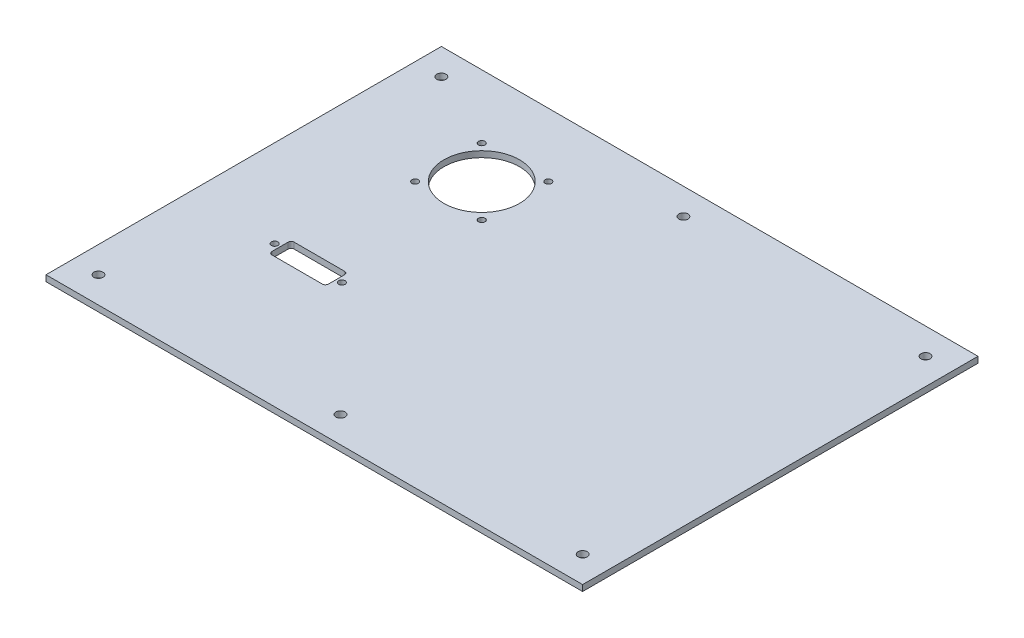
from build123d import *

# Parameters (mm, degrees)
SKETCH_1_W          = 266
SKETCH_1_H          = 196
SKETCH_1_R          = 2.25
EXTRUDE_1_DEPTH     = 3
SKETCH_3_R          = 18.75
SKETCH_3_R_2        = 1.6
CUT_EXTRUDE_1_DEPTH = 4
SKETCH1_R           = 1.6
SKETCH1_W           = 28
SKETCH1_H           = 11
CUT_EXTRUDE1_DEPTH  = 4
FILLET1_R           = 1.5


with BuildPart() as part:
    # Эскиз1 → Бобышка-Вытянуть1 (new body)
    with BuildSketch(Plane(origin=(0, 0, 0), x_dir=(1, 0, 0), z_dir=(0, 1, 0))):
        with Locations((133, 98)):
            Rectangle(SKETCH_1_W, SKETCH_1_H)
        with Locations((13, 183)):
            Circle(SKETCH_1_R, mode=Mode.SUBTRACT)
        with Locations((253, 183)):
            Circle(SKETCH_1_R, mode=Mode.SUBTRACT)
        with Locations((253, 13)):
            Circle(SKETCH_1_R, mode=Mode.SUBTRACT)
        with Locations((13, 13)):
            Circle(SKETCH_1_R, mode=Mode.SUBTRACT)
        with Locations((133, 13)):
            Circle(SKETCH_1_R, mode=Mode.SUBTRACT)
        with Locations((133, 183)):
            Circle(SKETCH_1_R, mode=Mode.SUBTRACT)
    extrude(amount=EXTRUDE_1_DEPTH)

    # Эскиз3 → Вырез-Вытянуть1 (cut, through all)
    with BuildSketch(Plane(origin=(0, 3, 0), x_dir=(1, 0, 0), z_dir=(0, 1, 0))):
        with Locations((68, 148)):
            Circle(SKETCH_3_R)
        with Locations((84.5, 164.5)):
            Circle(SKETCH_3_R_2)
        with Locations((84.5, 131.5)):
            Circle(SKETCH_3_R_2)
        with Locations((51.5, 131.5)):
            Circle(SKETCH_3_R_2)
        with Locations((51.5, 164.5)):
            Circle(SKETCH_3_R_2)
    extrude(amount=-CUT_EXTRUDE_1_DEPTH, mode=Mode.SUBTRACT)

    # Sketch1 → Cut-Extrude1 (cut, through all)
    with BuildSketch(Plane(origin=(0, 3, 0), x_dir=(1, 0, 0), z_dir=(0, 1, 0))):
        with Locations((43.34, 70)):
            Circle(SKETCH1_R)
        with Locations((76.66, 70)):
            Circle(SKETCH1_R)
        with Locations((60, 70)):
            Rectangle(SKETCH1_W, SKETCH1_H)
    extrude(amount=-CUT_EXTRUDE1_DEPTH, mode=Mode.SUBTRACT)

    # Fillet1
    fillet1_edges = [part.edges().sort_by_distance(p)[0] for p in [
        (46, 1.5, -75.5),
        (74, 1.5, -75.5),
        (74, 1.5, -64.5),
        (46, 1.5, -64.5),
    ]]
    fillet(fillet1_edges, radius=FILLET1_R)


solid = part.part
